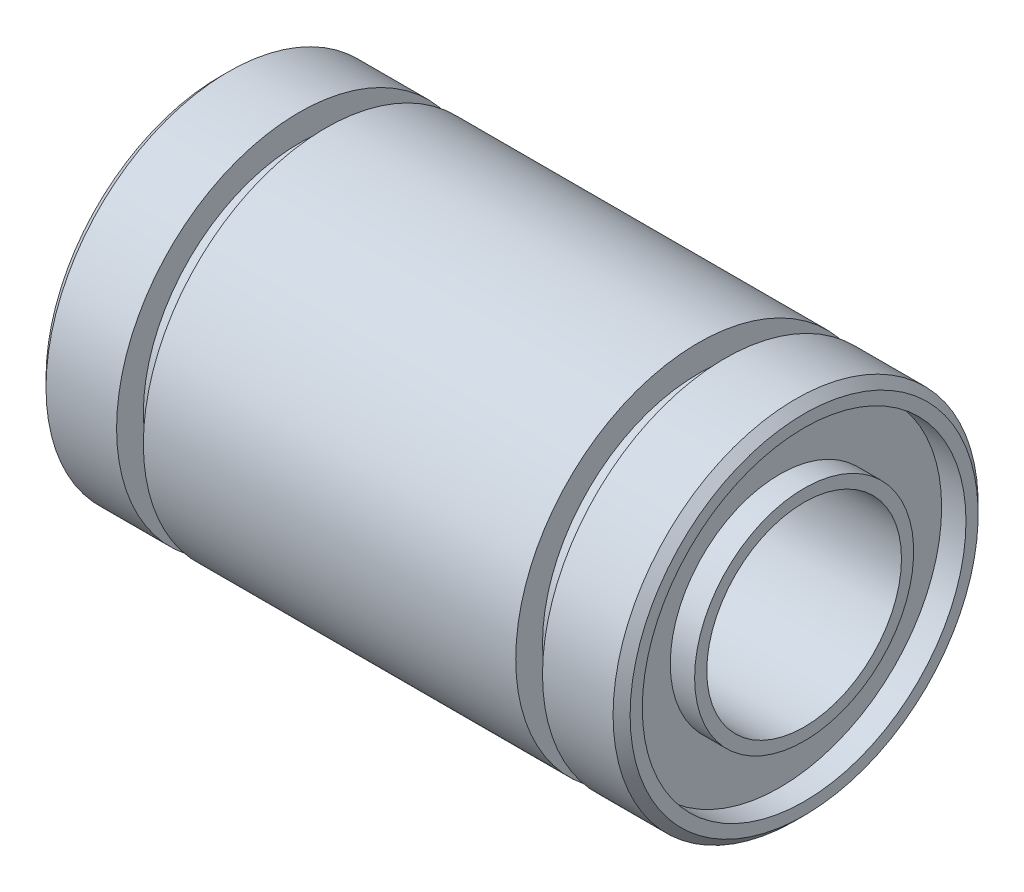
from build123d import *


with BuildPart() as part:
    # Sketch1 → Revolve1 (revolve)
    with BuildSketch(Plane.XY):
        Polygon((11.65, 7.5), (12, 7.15), (12, 6.65), (11, 6.65), (11, 4.5), (12, 4.5), (12, 4), (-12, 4), (-12, 4.5), (-11, 4.5), (-11, 6.65), (-12, 6.65), (-12, 7.15), (-11.65, 7.5), (-8.75, 7.5), (-8.75, 6.4), (-7.65, 6.4), (-7.65, 7.5), (7.65, 7.5), (7.65, 6.4), (8.75, 6.4), (8.75, 7.5), align=None)
    revolve(axis=Axis((-45.689505325, 0, 0), (1, 0, 0)))


solid = part.part
